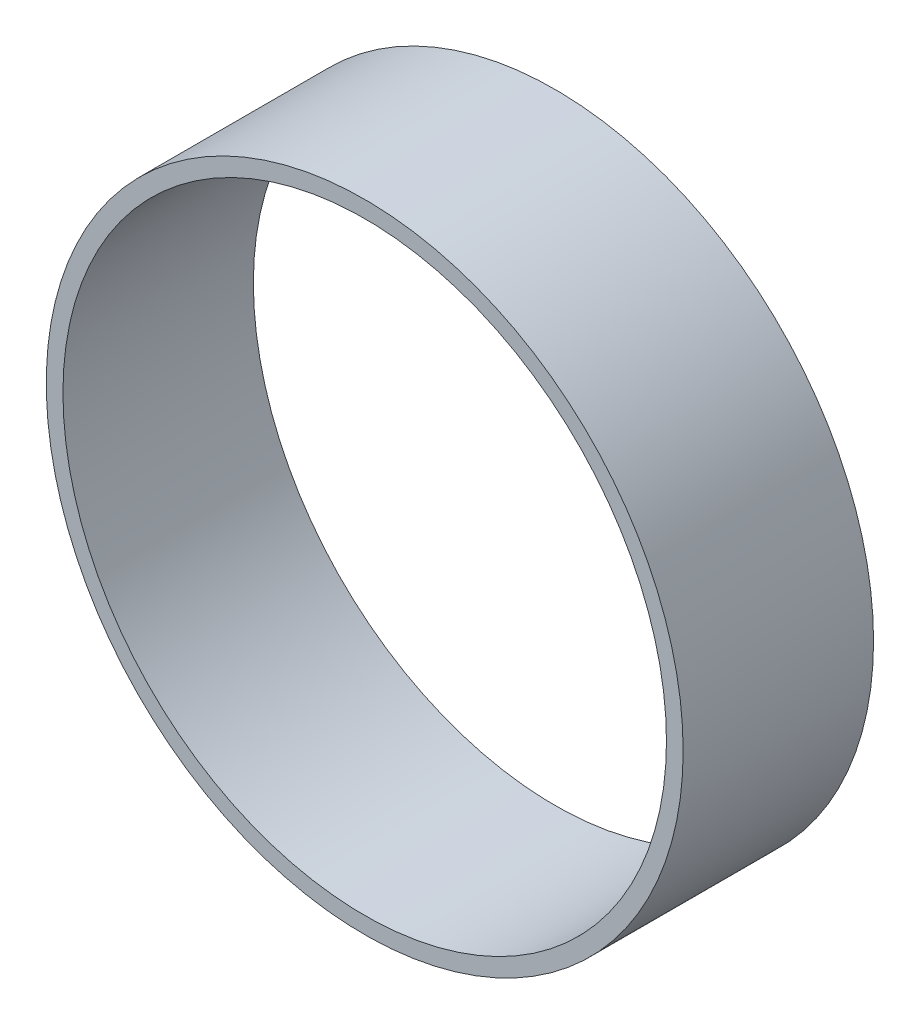
from build123d import *

# Parameters (mm, degrees)
SKETCH2_W = 2.54
SKETCH2_H = 29


with BuildPart() as part:
    # Sketch2 → Revolve1 (revolve)
    with BuildSketch(Plane(origin=(0, 0, 0), x_dir=(1, 0, 0), z_dir=(0, 1, 0))):
        with Locations((-47.23, 14.5)):
            Rectangle(SKETCH2_W, SKETCH2_H)
    revolve(axis=Axis((0, 0, 0), (0, 0, -1)))


solid = part.part
